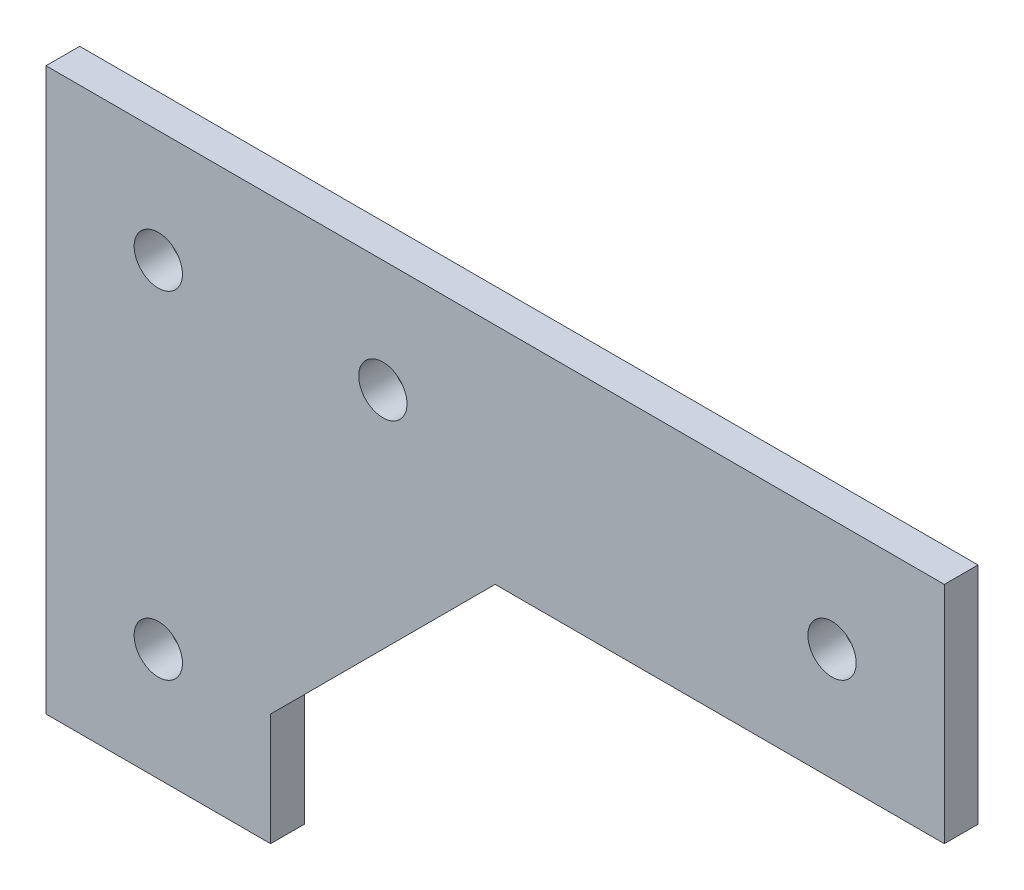
from build123d import *

# Parameters (mm, degrees)
SKETCH1_R      = 2.15
EXTRUDE1_DEPTH = 3


with BuildPart() as part:
    # Sketch1 → Extrude1 (new body)
    with BuildSketch(Plane.XY):
        Polygon((52.497048214, 165), (-27.502951786, 165), (-27.502951786, 115), (-7.502951786, 115), (-7.502951786, 125), (12.497048214, 145), (52.497048214, 145), align=None)
        with Locations((2.497048214, 155)):
            Circle(SKETCH1_R, mode=Mode.SUBTRACT)
        with Locations((42.497048214, 155)):
            Circle(SKETCH1_R, mode=Mode.SUBTRACT)
        with Locations((-17.502951786, 125)):
            Circle(SKETCH1_R, mode=Mode.SUBTRACT)
        with Locations((-17.502951786, 155)):
            Circle(SKETCH1_R, mode=Mode.SUBTRACT)
    extrude(amount=EXTRUDE1_DEPTH)


solid = part.part
